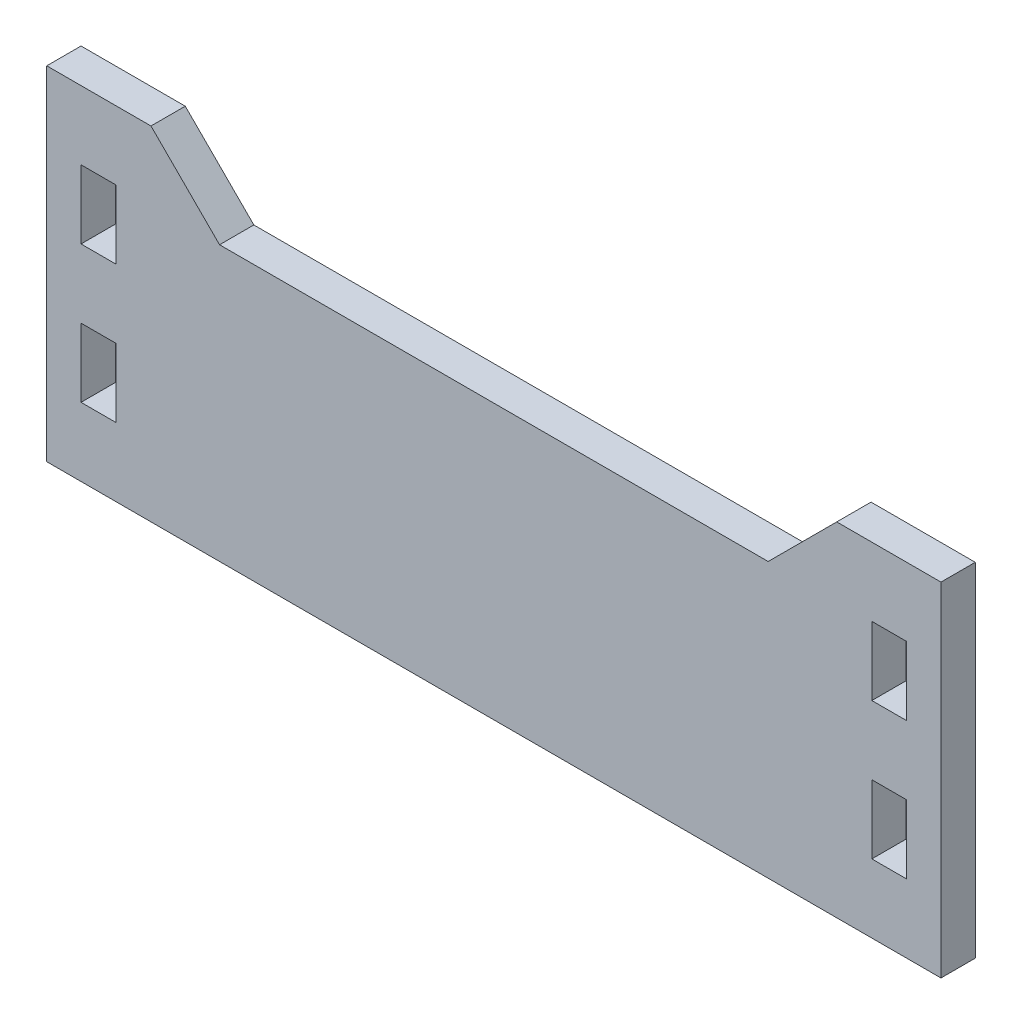
from build123d import *

# Parameters (mm, degrees)
SKETCH1_W           = 82.804
SKETCH1_H           = 31.75
BOSS_EXTRUDE1_DEPTH = 3.175
SKETCH2_W           = 3.2258
SKETCH2_H           = 6.35
CUT_FOR_TAB_DEPTH   = 4.175
CUT_EXTRUDE1_DEPTH  = 4.175


with BuildPart() as part:
    # Sketch1 → Boss-Extrude1 (new body)
    with BuildSketch(Plane.XY):
        Rectangle(SKETCH1_W, SKETCH1_H)
    extrude(amount=BOSS_EXTRUDE1_DEPTH)

    # Sketch2 → cut for tab (cut, through all)
    with BuildSketch(Plane.XY.offset(3.175)):
        with Locations((-36.6141, 6.35)):
            Rectangle(SKETCH2_W, SKETCH2_H)
        with Locations((-36.6141, -6.35)):
            Rectangle(SKETCH2_W, SKETCH2_H)
    cut_for_tab = extrude(amount=-CUT_FOR_TAB_DEPTH, mode=Mode.SUBTRACT)

    # Mirror1: cut for tab across plane
    add(cut_for_tab.mirror(Plane(origin=(0, 0, 0), x_dir=(0, 0, 1), z_dir=(1, 0, 0))), mode=Mode.SUBTRACT)

    # Sketch3 → Cut-Extrude1 (cut, through all)
    with BuildSketch(Plane.XY.offset(3.175)):
        Polygon((0, 15.875), (0, 9.525), (-25.4, 9.525), (-31.75, 15.875), align=None)
    cut_extrude1 = extrude(amount=-CUT_EXTRUDE1_DEPTH, mode=Mode.SUBTRACT)

    # Mirror2: Cut-Extrude1 across plane
    add(cut_extrude1.mirror(Plane(origin=(0, 0, 0), x_dir=(0, 0, 1), z_dir=(1, 0, 0))), mode=Mode.SUBTRACT)


solid = part.part
